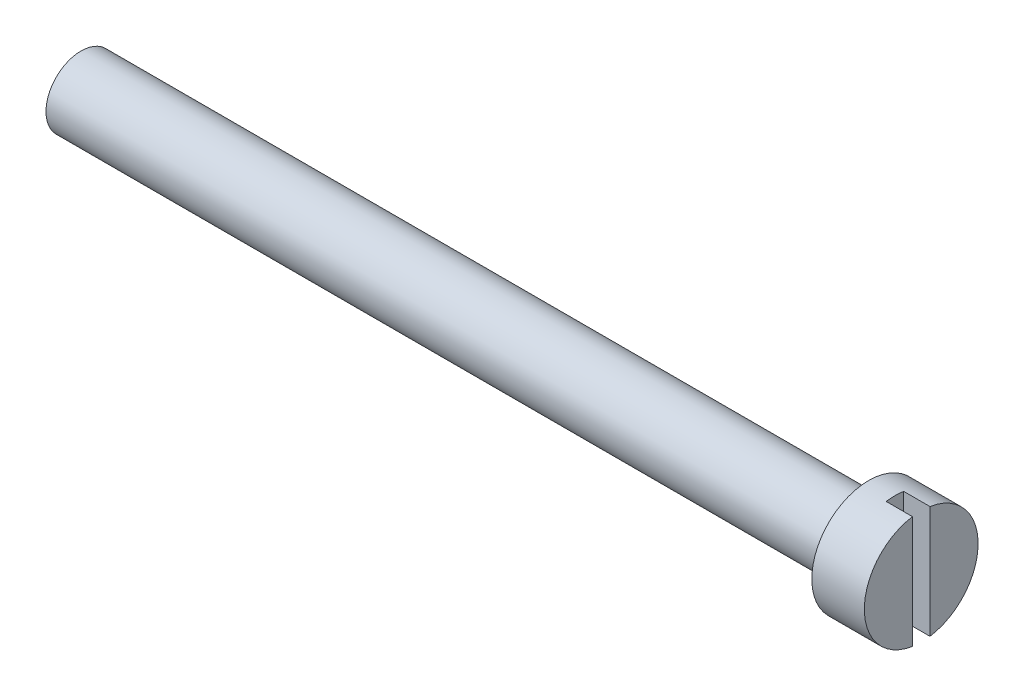
from build123d import *

# Parameters (mm, degrees)
SKETCH2_W          = 1
SKETCH2_H          = 6.5
CUT_EXTRUDE1_DEPTH = 1.5


with BuildPart() as part:
    # Sketch1 → Revolve1 (revolve)
    with BuildSketch(Plane.XY):
        Polygon((0, 0), (-48, 0), (-48, 2), (-3, 2), (-3, 3.25), (0, 3.25), align=None)
    revolve(axis=Axis((0, 0, 0), (-1, 0, 0)))

    # Sketch2 → Cut-Extrude1 (cut)
    with BuildSketch(Plane(origin=(0, 0, 0), x_dir=(0, 0, -1), z_dir=(1, 0, 0))):
        Rectangle(SKETCH2_W, SKETCH2_H)
    extrude(amount=-CUT_EXTRUDE1_DEPTH, mode=Mode.SUBTRACT)


solid = part.part
